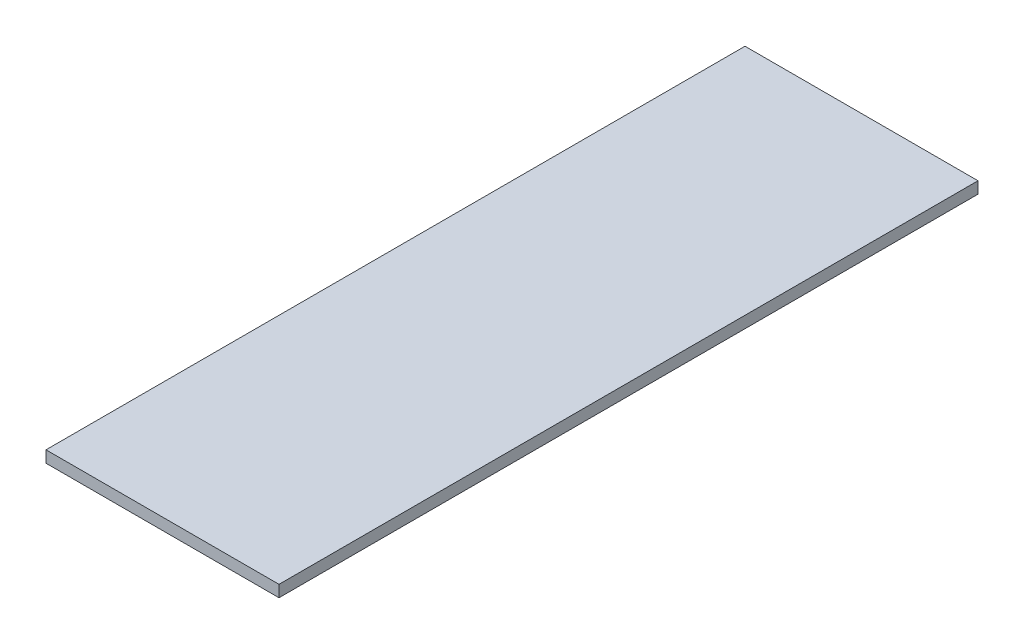
from build123d import *

# Parameters (mm, degrees)
SKETCH1_W           = 100
SKETCH1_H           = 300
BOSS_EXTRUDE1_DEPTH = 5


with BuildPart() as part:
    # Sketch1 → Boss-Extrude1 (new body)
    with BuildSketch(Plane(origin=(0, 0, 0), x_dir=(1, 0, 0), z_dir=(0, 1, 0))):
        Rectangle(SKETCH1_W, SKETCH1_H)
    extrude(amount=BOSS_EXTRUDE1_DEPTH)


solid = part.part
